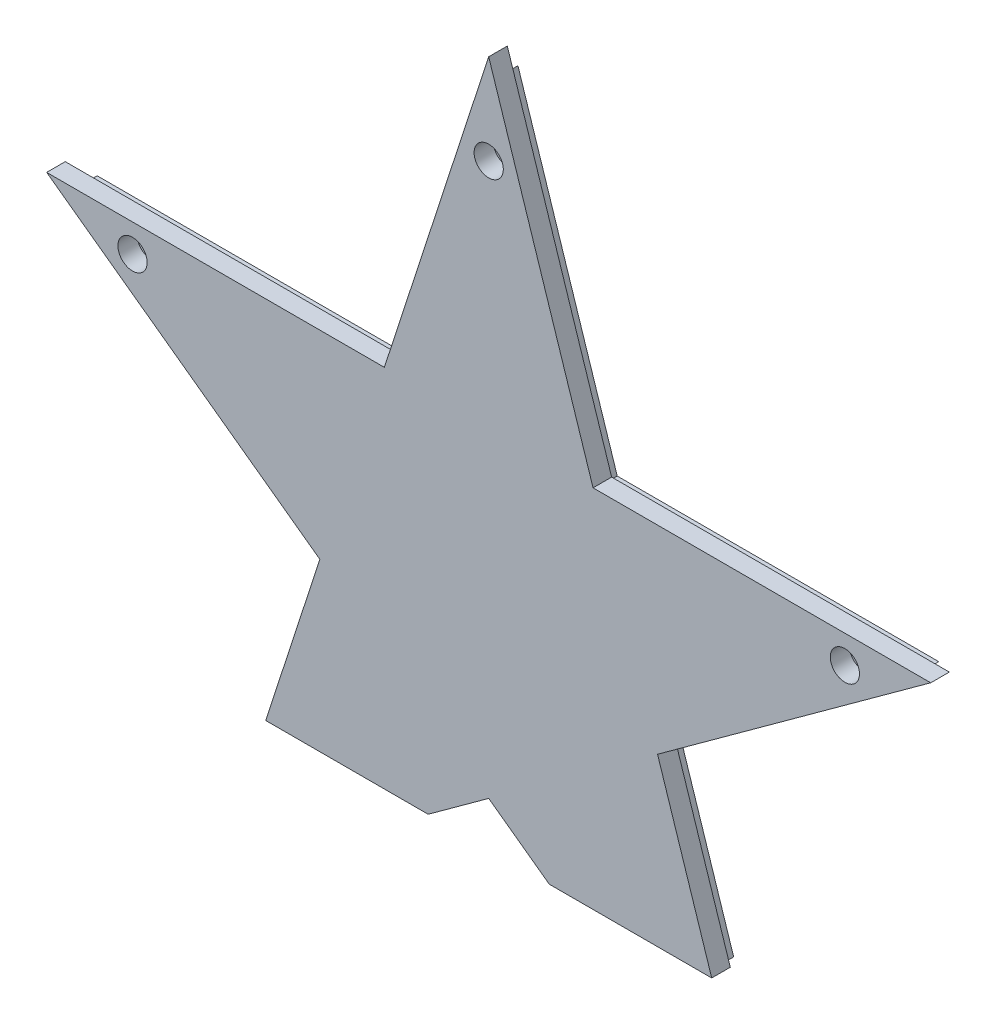
from build123d import *

# Parameters (mm, degrees)
SALIENTE_EXTRUIR1_DEPTH = 2
SALIENTE_EXTRUIR2_DEPTH = 3.5
CROQUIS2_R              = 1.85
CORTAR_EXTRUIR4_DEPTH   = 10
CROQUIS4_R              = 2.75
CORTAR_EXTRUIR5_DEPTH   = 3.6


with BuildPart() as part:
    # Croquis1 → Saliente-Extruir1 (new body)
    with BuildSketch(Plane.XY):
        Polygon((79.216456577, 25.738987008), (18.700468689, 25.738987008), (0, 83.293111629), (-18.700468689, 25.738987008), (-79.216456577, 25.738987008), (-30.257993944, -9.831418201), (-40.615003785, -41.707016882), (-13.615003785, -41.707016882), (0, -31.815137614), (13.615003785, -41.707016882), (40.615003785, -41.707016882), (30.257993944, -9.831418201), align=None)
    extrude(amount=SALIENTE_EXTRUIR1_DEPTH)

    # Croquis3 → Saliente-Extruir2 (add)
    with BuildSketch(Plane.XY.offset(2)):
        Polygon((-41.981904677, -41.707016882), (-11.403311683, -41.707016882), (0, -33.422025984), (11.403311683, -41.707016882), (41.981904677, -41.707016882), (31.7862356, -10.327974016), (83.217445176, 27.038987008), (19.644973975, 27.038987008), (0, 87.5), (-19.644973975, 27.038987008), (-83.217445176, 27.038987008), (-31.7862356, -10.327974016), align=None)
    extrude(amount=SALIENTE_EXTRUIR2_DEPTH)

    # Croquis2 → Cortar-Extruir4 (cut)
    with BuildSketch(Plane.XY.offset(5.5)):
        with Locations((0, 70.5)):
            Circle(CROQUIS2_R)
        with Locations((67.049484399, 21.785698103)):
            Circle(CROQUIS2_R)
        with Locations((-67.049484399, 21.785698103)):
            Circle(CROQUIS2_R)
    extrude(amount=-CORTAR_EXTRUIR4_DEPTH, mode=Mode.SUBTRACT)

    # Croquis4 → Cortar-Extruir5 (cut)
    with BuildSketch(Plane.XY.offset(5.5)):
        with Locations((67.049484399, 21.785698103)):
            Circle(CROQUIS4_R)
        with Locations((0, 70.5)):
            Circle(CROQUIS4_R)
        with Locations((-67.049484399, 21.785698103)):
            Circle(CROQUIS4_R)
    extrude(amount=-CORTAR_EXTRUIR5_DEPTH, mode=Mode.SUBTRACT)


solid = part.part
